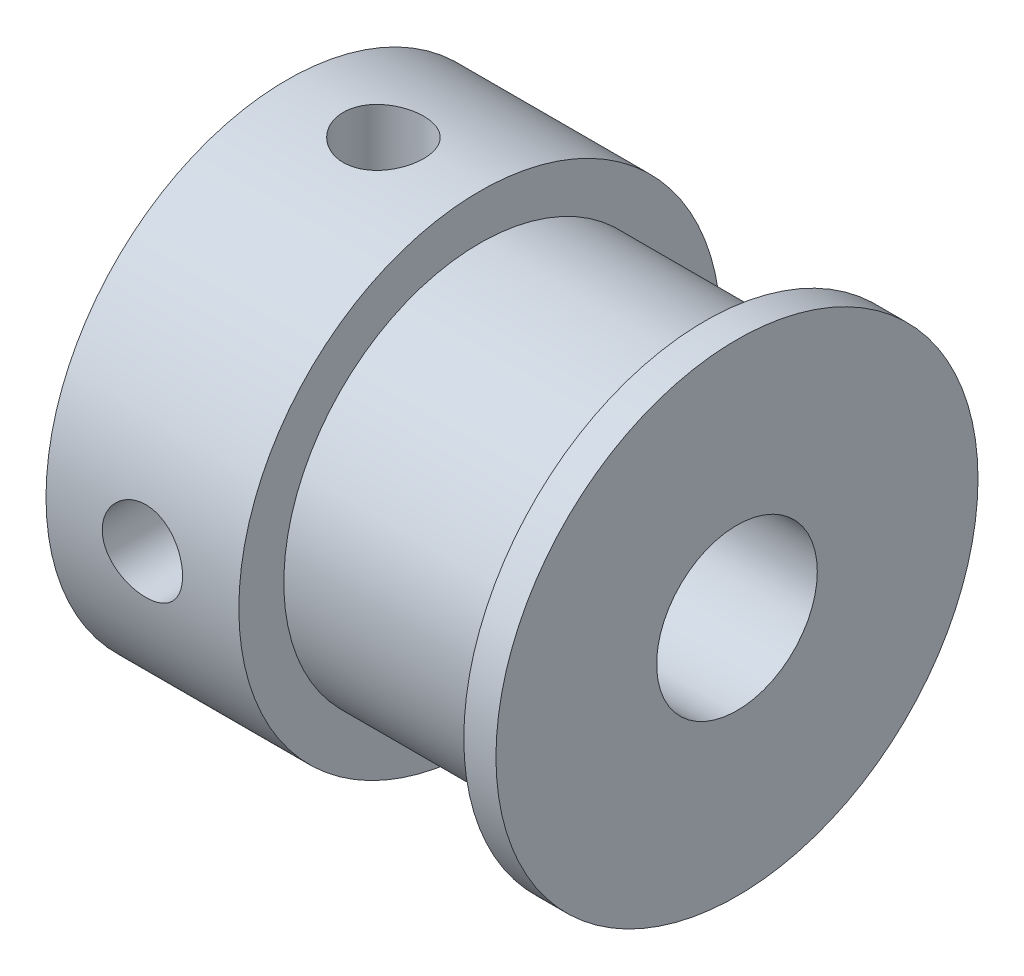
from build123d import *

# Parameters (mm, degrees)
SKETCH2_W = 1.25
SKETCH2_H = 7.5
SKETCH4_W = 1.25
SKETCH4_H = 7.5


with BuildPart() as part:
    # Sketch1 → Revolve1 (revolve)
    with BuildSketch(Plane.XY):
        Polygon((0, 2.5), (0, 7.5), (6, 7.5), (6, 6.1), (13, 6.1), (13, 7.5), (14, 7.5), (14, 2.5), align=None)
    revolve(axis=Axis((0, 0, 0), (-1, 0, 0)))

    # Sketch2 → M3x0.5 Tapped Hole1 (revolve, cut)
    with BuildSketch(Plane(origin=(3, 0, 0), x_dir=(0, 0, -1), z_dir=(1, 0, 0))):
        with Locations((0.625, 3.75)):
            Rectangle(SKETCH2_W, SKETCH2_H)
    revolve(axis=Axis((3, -6.35, 0), (0, 1, 0)), mode=Mode.SUBTRACT)

    # Sketch4 → M3x0.5 Tapped Hole2 (revolve, cut)
    with BuildSketch(Plane.YZ.offset(3)):
        with Locations((0.625, 3.75)):
            Rectangle(SKETCH4_W, SKETCH4_H)
    revolve(axis=Axis((3, 0, -6.35), (0, 0, 1)), mode=Mode.SUBTRACT)


solid = part.part
